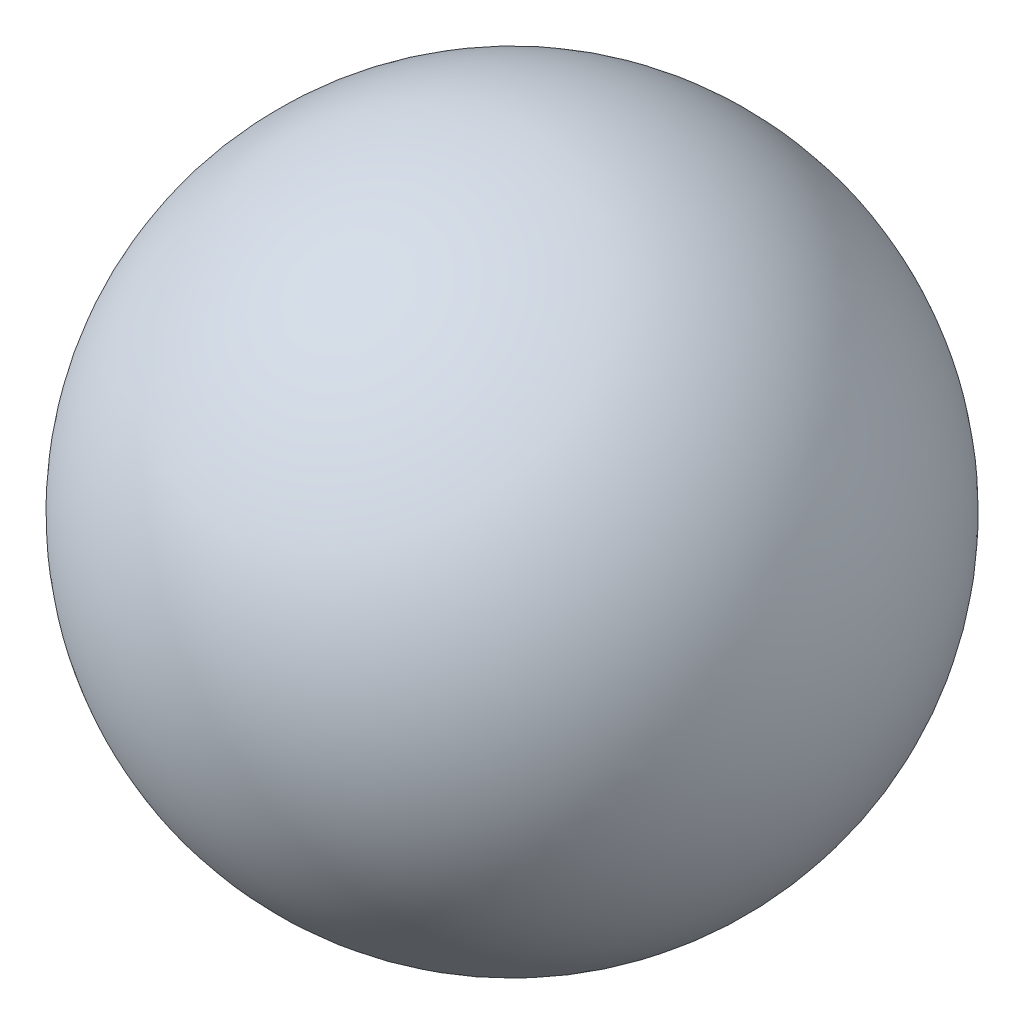
from build123d import *


with BuildPart() as part:
    # Sketch1 → Revolve1 (revolve)
    with BuildSketch(Plane(origin=(0, 0, 0), x_dir=(1, 0, 0), z_dir=(0, 1, 0))):
        with BuildLine():
            Line((0, 0), (0, 19.05))
            ThreePointArc((0, 19.05), (-9.525, 9.525), (0, 0))
        make_face()
    revolve(axis=Axis((0, 0, 0), (0, 0, -1)))


solid = part.part
